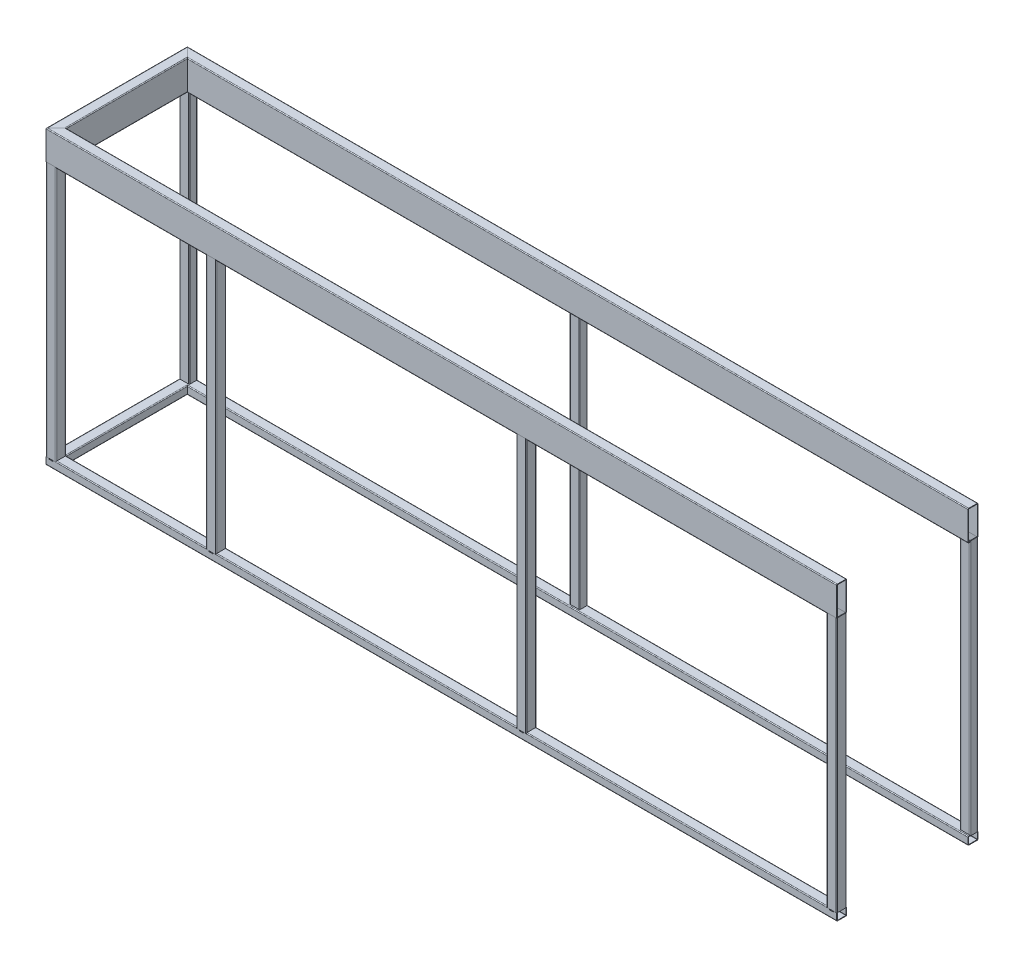
from build123d import *

# Parameters (mm, degrees)
VIERKANTROHRE_150X50X3_1_DEPTH        = 3981.056941504
VIERKANTROHRE_150X50X3_1_2_DEPTH      = 816.113883008
VIERKANTROHRE_150X50X3_1_3_DEPTH      = 3901
VIERKANTROHRE_150X50X3_1_3_DEPTH_BACK = 80.056941504
VIERKANTROHRE_50X50X3_1_DEPTH         = 1363
VIERKANTROHRE_50X50X3_1_2_DEPTH       = 1363
VIERKANTROHRE_50X50X3_1_3_DEPTH       = 1363
VIERKANTROHRE_50X50X3_1_4_DEPTH       = 1363
VIERKANTROHRE_40X50X3_1_DEPTH         = 3934.015621187
VIERKANTROHRE_40X50X3_1_2_DEPTH       = 722.031242374
VIERKANTROHRE_40X50X3_1_3_DEPTH       = 3901
VIERKANTROHRE_40X50X3_1_3_DEPTH_BACK  = 33.015621187
PART_START                            = 316.227766017
PART_RUN_ON_DEPTH                     = 341.227766017
BODY_START                            = 3584.772233983
BODY_3_RUN_ON_DEPTH                   = 341.227766017
BODY_START_2                          = 128.062484749
BODY_8_RUN_ON_DEPTH                   = 153.062484749
BODY_START_3                          = 3772.937515251
BODY_10_RUN_ON_DEPTH                  = 153.062484749
SKIZZE16_W                            = 50
SKIZZE16_H                            = 4
SCHNITT_LINEAR_AUSTRAGEN1_DEPTH       = 50
SKIZZE17_W                            = 50
SKIZZE17_H                            = 4
SCHNITT_LINEAR_AUSTRAGEN2_DEPTH       = 40
VIERKANTROHRE_40X50X3_5_DEPTH         = 1363
VIERKANTROHRE_40X50X3_5_2_DEPTH       = 1363
VIERKANTROHRE_40X50X3_5_3_DEPTH       = 1363


with BuildPart() as part:
    # Skizze1 on segment 1 (carried to segment 1) → Vierkantrohre 150X50X3(1) (new body)
    with BuildSketch(Plane(origin=(3901, 0, 0), x_dir=(0, 1, 0), z_dir=(-1, 0, 0))):
        with BuildLine():
            Line((-71, 25), (71, 25))
            ThreePointArc((71, 25), (73.828427125, 23.828427125), (75, 21))
            Line((75, 21), (75, -21))
            ThreePointArc((75, -21), (73.828427125, -23.828427125), (71, -25))
            Line((71, -25), (-71, -25))
            ThreePointArc((-71, -25), (-73.828427125, -23.828427125), (-75, -21))
            Line((-75, -21), (-75, 21))
            ThreePointArc((-75, 21), (-73.828427125, 23.828427125), (-71, 25))
        make_face()
        with BuildLine():
            Line((-71, 22), (71, 22))
            ThreePointArc((71, 22), (71.707106781, 21.707106781), (72, 21))
            Line((72, 21), (72, -21))
            ThreePointArc((72, -21), (71.707106781, -21.707106781), (71, -22))
            Line((71, -22), (-71, -22))
            ThreePointArc((-71, -22), (-71.707106781, -21.707106781), (-72, -21))
            Line((-72, -21), (-72, 21))
            ThreePointArc((-72, 21), (-71.707106781, 21.707106781), (-71, 22))
        make_face(mode=Mode.SUBTRACT)
    extrude(amount=VIERKANTROHRE_150X50X3_1_DEPTH)

    # Vierkantrohre 150X50X3(1) mitre 1
    split(bisect_by=Plane(origin=(0, 0, 0), x_dir=(0, 1, 0), z_dir=(0.707106781, 0, 0.707106781)), keep=Keep.TOP)

    # part cut square before the run-on
    split(bisect_by=Plane(origin=(3584.772233983, 0, 0), x_dir=(0, -1, 0), z_dir=(-1, 0, 0)), keep=Keep.TOP)

    # Skizze1 on segment 1 (carried to segment 1) → part run on (add)
    with BuildSketch(Plane(origin=(3901, 0, 0), x_dir=(0, 1, 0), z_dir=(-1, 0, 0)).offset(PART_START)):
        with BuildLine():
            Line((-71, 25), (71, 25))
            ThreePointArc((71, 25), (73.828427125, 23.828427125), (75, 21))
            Line((75, 21), (75, -21))
            ThreePointArc((75, -21), (73.828427125, -23.828427125), (71, -25))
            Line((71, -25), (-71, -25))
            ThreePointArc((-71, -25), (-73.828427125, -23.828427125), (-75, -21))
            Line((-75, -21), (-75, 21))
            ThreePointArc((-75, 21), (-73.828427125, 23.828427125), (-71, 25))
        make_face()
        with BuildLine():
            Line((-71, 22), (71, 22))
            ThreePointArc((71, 22), (71.707106781, 21.707106781), (72, 21))
            Line((72, 21), (72, -21))
            ThreePointArc((72, -21), (71.707106781, -21.707106781), (71, -22))
            Line((71, -22), (-71, -22))
            ThreePointArc((-71, -22), (-71.707106781, -21.707106781), (-72, -21))
            Line((-72, -21), (-72, 21))
            ThreePointArc((-72, 21), (-71.707106781, 21.707106781), (-71, 22))
        make_face(mode=Mode.SUBTRACT)
    extrude(amount=-PART_RUN_ON_DEPTH)


with BuildPart() as body_2:
    # Skizze1 on segment 2 (carried to segment 2) → Vierkantrohre 150X50X3_1 2 (new body)
    with BuildSketch(Plane.YX.offset(-80.056941504)):
        with BuildLine():
            Line((-71, 25), (71, 25))
            ThreePointArc((71, 25), (73.828427125, 23.828427125), (75, 21))
            Line((75, 21), (75, -21))
            ThreePointArc((75, -21), (73.828427125, -23.828427125), (71, -25))
            Line((71, -25), (-71, -25))
            ThreePointArc((-71, -25), (-73.828427125, -23.828427125), (-75, -21))
            Line((-75, -21), (-75, 21))
            ThreePointArc((-75, 21), (-73.828427125, 23.828427125), (-71, 25))
        make_face()
        with BuildLine():
            Line((-71, 22), (71, 22))
            ThreePointArc((71, 22), (71.707106781, 21.707106781), (72, 21))
            Line((72, 21), (72, -21))
            ThreePointArc((72, -21), (71.707106781, -21.707106781), (71, -22))
            Line((71, -22), (-71, -22))
            ThreePointArc((-71, -22), (-71.707106781, -21.707106781), (-72, -21))
            Line((-72, -21), (-72, 21))
            ThreePointArc((-72, 21), (-71.707106781, 21.707106781), (-71, 22))
        make_face(mode=Mode.SUBTRACT)
    extrude(amount=VIERKANTROHRE_150X50X3_1_2_DEPTH)

    # Vierkantrohre 150X50X3_1 2 mitre 1
    split(bisect_by=Plane(origin=(0, 0, 0), x_dir=(0, -1, 0), z_dir=(-0.707106781, 0, -0.707106781)), keep=Keep.TOP)

    # Vierkantrohre 150X50X3_1 2 mitre 2
    split(bisect_by=Plane(origin=(0, 0, -656), x_dir=(0, -1, 0), z_dir=(-0.707106781, 0, 0.707106781)), keep=Keep.TOP)


with BuildPart() as body_3:
    # Skizze1 → Vierkantrohre 150X50X3_1 3 (new, two sides)
    with BuildSketch(Plane(origin=(0, 0, -656), x_dir=(0, 1, 0), z_dir=(1, 0, 0))) as vierkantrohre_150x50x3_1_3_sk:
        with BuildLine():
            Line((-71, 25), (71, 25))
            ThreePointArc((71, 25), (73.828427125, 23.828427125), (75, 21))
            Line((75, 21), (75, -21))
            ThreePointArc((75, -21), (73.828427125, -23.828427125), (71, -25))
            Line((71, -25), (-71, -25))
            ThreePointArc((-71, -25), (-73.828427125, -23.828427125), (-75, -21))
            Line((-75, -21), (-75, 21))
            ThreePointArc((-75, 21), (-73.828427125, 23.828427125), (-71, 25))
        make_face()
        with BuildLine():
            Line((-71, 22), (71, 22))
            ThreePointArc((71, 22), (71.707106781, 21.707106781), (72, 21))
            Line((72, 21), (72, -21))
            ThreePointArc((72, -21), (71.707106781, -21.707106781), (71, -22))
            Line((71, -22), (-71, -22))
            ThreePointArc((-71, -22), (-71.707106781, -21.707106781), (-72, -21))
            Line((-72, -21), (-72, 21))
            ThreePointArc((-72, 21), (-71.707106781, 21.707106781), (-71, 22))
        make_face(mode=Mode.SUBTRACT)
    extrude(amount=VIERKANTROHRE_150X50X3_1_3_DEPTH)
    extrude(vierkantrohre_150x50x3_1_3_sk.sketch, amount=-VIERKANTROHRE_150X50X3_1_3_DEPTH_BACK)

    # Vierkantrohre 150X50X3_1 3 mitre 1
    split(bisect_by=Plane(origin=(0, 0, -656), x_dir=(0, 1, 0), z_dir=(0.707106781, 0, -0.707106781)), keep=Keep.TOP)

    # body 3 cut square before the run-on
    split(bisect_by=Plane(origin=(3584.772233983, 0, -656), x_dir=(0, -1, 0), z_dir=(-1, 0, 0)), keep=Keep.TOP)

    # Skizze1 → body 3 run on (add)
    with BuildSketch(Plane(origin=(0, 0, -656), x_dir=(0, 1, 0), z_dir=(1, 0, 0)).offset(BODY_START)):
        with BuildLine():
            Line((-71, 25), (71, 25))
            ThreePointArc((71, 25), (73.828427125, 23.828427125), (75, 21))
            Line((75, 21), (75, -21))
            ThreePointArc((75, -21), (73.828427125, -23.828427125), (71, -25))
            Line((71, -25), (-71, -25))
            ThreePointArc((-71, -25), (-73.828427125, -23.828427125), (-75, -21))
            Line((-75, -21), (-75, 21))
            ThreePointArc((-75, 21), (-73.828427125, 23.828427125), (-71, 25))
        make_face()
        with BuildLine():
            Line((-71, 22), (71, 22))
            ThreePointArc((71, 22), (71.707106781, 21.707106781), (72, 21))
            Line((72, 21), (72, -21))
            ThreePointArc((72, -21), (71.707106781, -21.707106781), (71, -22))
            Line((71, -22), (-71, -22))
            ThreePointArc((-71, -22), (-71.707106781, -21.707106781), (-72, -21))
            Line((-72, -21), (-72, 21))
            ThreePointArc((-72, 21), (-71.707106781, 21.707106781), (-71, 22))
        make_face(mode=Mode.SUBTRACT)
    extrude(amount=BODY_3_RUN_ON_DEPTH)


with BuildPart() as body_4:
    # Skizze13 → Vierkantrohre 50X50X3(1) (new body)
    with BuildSketch(Plane.XZ):
        with BuildLine():
            Line((-21, 25), (21, 25))
            ThreePointArc((21, 25), (23.828427125, 23.828427125), (25, 21))
            Line((25, 21), (25, -21))
            ThreePointArc((25, -21), (23.828427125, -23.828427125), (21, -25))
            Line((21, -25), (-21, -25))
            ThreePointArc((-21, -25), (-23.828427125, -23.828427125), (-25, -21))
            Line((-25, -21), (-25, 21))
            ThreePointArc((-25, 21), (-23.828427125, 23.828427125), (-21, 25))
        make_face()
        with BuildLine():
            Line((-21, 22), (21, 22))
            ThreePointArc((21, 22), (21.707106781, 21.707106781), (22, 21))
            Line((22, 21), (22, -21))
            ThreePointArc((22, -21), (21.707106781, -21.707106781), (21, -22))
            Line((21, -22), (-21, -22))
            ThreePointArc((-21, -22), (-21.707106781, -21.707106781), (-22, -21))
            Line((-22, -21), (-22, 21))
            ThreePointArc((-22, 21), (-21.707106781, 21.707106781), (-21, 22))
        make_face(mode=Mode.SUBTRACT)
    extrude(amount=VIERKANTROHRE_50X50X3_1_DEPTH)

    # Trimmen/Verlängern5
    split(bisect_by=Plane(origin=(3883.5, -1347, 23.5), x_dir=(-1, 0, 0), z_dir=(0, 1, 0)), keep=Keep.TOP)

    # Trimmen_Verl_ngern5 3
    split(bisect_by=Plane(origin=(3901, -71, 23.5), x_dir=(1, 0, 0), z_dir=(0, -1, 0)), keep=Keep.TOP)


with BuildPart() as body_5:
    # Skizze13 on segment 2 (carried to segment 2) → Vierkantrohre 50X50X3_1 2 (new body)
    with BuildSketch(Plane(origin=(800, 0, 0), x_dir=(1, 0, 0), z_dir=(0, -1, 0))):
        with BuildLine():
            Line((-21, 25), (21, 25))
            ThreePointArc((21, 25), (23.828427125, 23.828427125), (25, 21))
            Line((25, 21), (25, -21))
            ThreePointArc((25, -21), (23.828427125, -23.828427125), (21, -25))
            Line((21, -25), (-21, -25))
            ThreePointArc((-21, -25), (-23.828427125, -23.828427125), (-25, -21))
            Line((-25, -21), (-25, 21))
            ThreePointArc((-25, 21), (-23.828427125, 23.828427125), (-21, 25))
        make_face()
        with BuildLine():
            Line((-21, 22), (21, 22))
            ThreePointArc((21, 22), (21.707106781, 21.707106781), (22, 21))
            Line((22, 21), (22, -21))
            ThreePointArc((22, -21), (21.707106781, -21.707106781), (21, -22))
            Line((21, -22), (-21, -22))
            ThreePointArc((-21, -22), (-21.707106781, -21.707106781), (-22, -21))
            Line((-22, -21), (-22, 21))
            ThreePointArc((-22, 21), (-21.707106781, 21.707106781), (-21, 22))
        make_face(mode=Mode.SUBTRACT)
    extrude(amount=VIERKANTROHRE_50X50X3_1_2_DEPTH)

    # Trimmen/Verlängern5
    split(bisect_by=Plane(origin=(3883.5, -1347, 23.5), x_dir=(-1, 0, 0), z_dir=(0, 1, 0)), keep=Keep.TOP)

    # Trimmen_Verl_ngern5 3
    split(bisect_by=Plane(origin=(3901, -71, 23.5), x_dir=(1, 0, 0), z_dir=(0, -1, 0)), keep=Keep.TOP)


with BuildPart() as body_6:
    # Skizze13 on segment 3 (carried to segment 3) → Vierkantrohre 50X50X3_1 3 (new body)
    with BuildSketch(Plane(origin=(2350, 0, 0), x_dir=(1, 0, 0), z_dir=(0, -1, 0))):
        with BuildLine():
            Line((-21, 25), (21, 25))
            ThreePointArc((21, 25), (23.828427125, 23.828427125), (25, 21))
            Line((25, 21), (25, -21))
            ThreePointArc((25, -21), (23.828427125, -23.828427125), (21, -25))
            Line((21, -25), (-21, -25))
            ThreePointArc((-21, -25), (-23.828427125, -23.828427125), (-25, -21))
            Line((-25, -21), (-25, 21))
            ThreePointArc((-25, 21), (-23.828427125, 23.828427125), (-21, 25))
        make_face()
        with BuildLine():
            Line((-21, 22), (21, 22))
            ThreePointArc((21, 22), (21.707106781, 21.707106781), (22, 21))
            Line((22, 21), (22, -21))
            ThreePointArc((22, -21), (21.707106781, -21.707106781), (21, -22))
            Line((21, -22), (-21, -22))
            ThreePointArc((-21, -22), (-21.707106781, -21.707106781), (-22, -21))
            Line((-22, -21), (-22, 21))
            ThreePointArc((-22, 21), (-21.707106781, 21.707106781), (-21, 22))
        make_face(mode=Mode.SUBTRACT)
    extrude(amount=VIERKANTROHRE_50X50X3_1_3_DEPTH)

    # Trimmen/Verlängern5
    split(bisect_by=Plane(origin=(3883.5, -1347, 23.5), x_dir=(-1, 0, 0), z_dir=(0, 1, 0)), keep=Keep.TOP)

    # Trimmen_Verl_ngern5 3
    split(bisect_by=Plane(origin=(3901, -71, 23.5), x_dir=(1, 0, 0), z_dir=(0, -1, 0)), keep=Keep.TOP)


with BuildPart() as body_7:
    # Skizze13 on segment 4 (carried to segment 4) → Vierkantrohre 50X50X3_1 4 (new body)
    with BuildSketch(Plane(origin=(3901, 0, 0), x_dir=(1, 0, 0), z_dir=(0, -1, 0))):
        with BuildLine():
            Line((-21, 25), (21, 25))
            ThreePointArc((21, 25), (23.828427125, 23.828427125), (25, 21))
            Line((25, 21), (25, -21))
            ThreePointArc((25, -21), (23.828427125, -23.828427125), (21, -25))
            Line((21, -25), (-21, -25))
            ThreePointArc((-21, -25), (-23.828427125, -23.828427125), (-25, -21))
            Line((-25, -21), (-25, 21))
            ThreePointArc((-25, 21), (-23.828427125, 23.828427125), (-21, 25))
        make_face()
        with BuildLine():
            Line((-21, 22), (21, 22))
            ThreePointArc((21, 22), (21.707106781, 21.707106781), (22, 21))
            Line((22, 21), (22, -21))
            ThreePointArc((22, -21), (21.707106781, -21.707106781), (21, -22))
            Line((21, -22), (-21, -22))
            ThreePointArc((-21, -22), (-21.707106781, -21.707106781), (-22, -21))
            Line((-22, -21), (-22, 21))
            ThreePointArc((-22, 21), (-21.707106781, 21.707106781), (-21, 22))
        make_face(mode=Mode.SUBTRACT)
    extrude(amount=VIERKANTROHRE_50X50X3_1_4_DEPTH)

    # Trimmen/Verlängern5
    split(bisect_by=Plane(origin=(3883.5, -1347, 23.5), x_dir=(-1, 0, 0), z_dir=(0, 1, 0)), keep=Keep.TOP)

    # Trimmen_Verl_ngern5 3
    split(bisect_by=Plane(origin=(3901, -71, 23.5), x_dir=(1, 0, 0), z_dir=(0, -1, 0)), keep=Keep.TOP)


with BuildPart() as body_8:
    # Skizze15 on segment 1 (carried to segment 1) → Vierkantrohre 40X50X3(1) (new body)
    with BuildSketch(Plane(origin=(3901, -1363, 0), x_dir=(0, 1, 0), z_dir=(-1, 0, 0))):
        with BuildLine():
            Line((-16, 25), (16, 25))
            ThreePointArc((16, 25), (18.828427125, 23.828427125), (20, 21))
            Line((20, 21), (20, -21))
            ThreePointArc((20, -21), (18.828427125, -23.828427125), (16, -25))
            Line((16, -25), (-16, -25))
            ThreePointArc((-16, -25), (-18.828427125, -23.828427125), (-20, -21))
            Line((-20, -21), (-20, 21))
            ThreePointArc((-20, 21), (-18.828427125, 23.828427125), (-16, 25))
        make_face()
        with BuildLine():
            Line((-16, 22), (16, 22))
            ThreePointArc((16, 22), (16.707106781, 21.707106781), (17, 21))
            Line((17, 21), (17, -21))
            ThreePointArc((17, -21), (16.707106781, -21.707106781), (16, -22))
            Line((16, -22), (-16, -22))
            ThreePointArc((-16, -22), (-16.707106781, -21.707106781), (-17, -21))
            Line((-17, -21), (-17, 21))
            ThreePointArc((-17, 21), (-16.707106781, 21.707106781), (-16, 22))
        make_face(mode=Mode.SUBTRACT)
    extrude(amount=VIERKANTROHRE_40X50X3_1_DEPTH)

    # Vierkantrohre 40X50X3(1) mitre 1
    split(bisect_by=Plane(origin=(0, -1363, 0), x_dir=(0, 1, 0), z_dir=(0.707106781, 0, 0.707106781)), keep=Keep.TOP)

    # body 8 cut square before the run-on
    split(bisect_by=Plane(origin=(3772.937515251, -1363, 0), x_dir=(0, -1, 0), z_dir=(-1, 0, 0)), keep=Keep.TOP)

    # Skizze15 on segment 1 (carried to segment 1) → body 8 run on (add)
    with BuildSketch(Plane(origin=(3901, -1363, 0), x_dir=(0, 1, 0), z_dir=(-1, 0, 0)).offset(BODY_START_2)):
        with BuildLine():
            Line((-16, 25), (16, 25))
            ThreePointArc((16, 25), (18.828427125, 23.828427125), (20, 21))
            Line((20, 21), (20, -21))
            ThreePointArc((20, -21), (18.828427125, -23.828427125), (16, -25))
            Line((16, -25), (-16, -25))
            ThreePointArc((-16, -25), (-18.828427125, -23.828427125), (-20, -21))
            Line((-20, -21), (-20, 21))
            ThreePointArc((-20, 21), (-18.828427125, 23.828427125), (-16, 25))
        make_face()
        with BuildLine():
            Line((-16, 22), (16, 22))
            ThreePointArc((16, 22), (16.707106781, 21.707106781), (17, 21))
            Line((17, 21), (17, -21))
            ThreePointArc((17, -21), (16.707106781, -21.707106781), (16, -22))
            Line((16, -22), (-16, -22))
            ThreePointArc((-16, -22), (-16.707106781, -21.707106781), (-17, -21))
            Line((-17, -21), (-17, 21))
            ThreePointArc((-17, 21), (-16.707106781, 21.707106781), (-16, 22))
        make_face(mode=Mode.SUBTRACT)
    extrude(amount=-BODY_8_RUN_ON_DEPTH)


with BuildPart() as body_9:
    # Skizze15 on segment 2 (carried to segment 2) → Vierkantrohre 40X50X3_1 2 (new body)
    with BuildSketch(Plane(origin=(0, -1363, 33.015621187), x_dir=(0, 1, 0), z_dir=(0, 0, -1))):
        with BuildLine():
            Line((-16, 25), (16, 25))
            ThreePointArc((16, 25), (18.828427125, 23.828427125), (20, 21))
            Line((20, 21), (20, -21))
            ThreePointArc((20, -21), (18.828427125, -23.828427125), (16, -25))
            Line((16, -25), (-16, -25))
            ThreePointArc((-16, -25), (-18.828427125, -23.828427125), (-20, -21))
            Line((-20, -21), (-20, 21))
            ThreePointArc((-20, 21), (-18.828427125, 23.828427125), (-16, 25))
        make_face()
        with BuildLine():
            Line((-16, 22), (16, 22))
            ThreePointArc((16, 22), (16.707106781, 21.707106781), (17, 21))
            Line((17, 21), (17, -21))
            ThreePointArc((17, -21), (16.707106781, -21.707106781), (16, -22))
            Line((16, -22), (-16, -22))
            ThreePointArc((-16, -22), (-16.707106781, -21.707106781), (-17, -21))
            Line((-17, -21), (-17, 21))
            ThreePointArc((-17, 21), (-16.707106781, 21.707106781), (-16, 22))
        make_face(mode=Mode.SUBTRACT)
    extrude(amount=VIERKANTROHRE_40X50X3_1_2_DEPTH)

    # Vierkantrohre 40X50X3_1 2 mitre 1
    split(bisect_by=Plane(origin=(0, -1363, -656), x_dir=(0, -1, 0), z_dir=(-0.707106781, 0, 0.707106781)), keep=Keep.TOP)

    # Vierkantrohre 40X50X3_1 2 mitre 2
    split(bisect_by=Plane(origin=(0, -1363, 0), x_dir=(0, -1, 0), z_dir=(-0.707106781, 0, -0.707106781)), keep=Keep.TOP)


with BuildPart() as body_10:
    # Skizze15 → Vierkantrohre 40X50X3_1 3 (new, two sides)
    with BuildSketch(Plane(origin=(0, -1363, -656), x_dir=(0, 1, 0), z_dir=(1, 0, 0))) as vierkantrohre_40x50x3_1_3_sk:
        with BuildLine():
            Line((-16, 25), (16, 25))
            ThreePointArc((16, 25), (18.828427125, 23.828427125), (20, 21))
            Line((20, 21), (20, -21))
            ThreePointArc((20, -21), (18.828427125, -23.828427125), (16, -25))
            Line((16, -25), (-16, -25))
            ThreePointArc((-16, -25), (-18.828427125, -23.828427125), (-20, -21))
            Line((-20, -21), (-20, 21))
            ThreePointArc((-20, 21), (-18.828427125, 23.828427125), (-16, 25))
        make_face()
        with BuildLine():
            Line((-16, 22), (16, 22))
            ThreePointArc((16, 22), (16.707106781, 21.707106781), (17, 21))
            Line((17, 21), (17, -21))
            ThreePointArc((17, -21), (16.707106781, -21.707106781), (16, -22))
            Line((16, -22), (-16, -22))
            ThreePointArc((-16, -22), (-16.707106781, -21.707106781), (-17, -21))
            Line((-17, -21), (-17, 21))
            ThreePointArc((-17, 21), (-16.707106781, 21.707106781), (-16, 22))
        make_face(mode=Mode.SUBTRACT)
    extrude(amount=VIERKANTROHRE_40X50X3_1_3_DEPTH)
    extrude(vierkantrohre_40x50x3_1_3_sk.sketch, amount=-VIERKANTROHRE_40X50X3_1_3_DEPTH_BACK)

    # Vierkantrohre 40X50X3_1 3 mitre 1
    split(bisect_by=Plane(origin=(0, -1363, -656), x_dir=(0, 1, 0), z_dir=(0.707106781, 0, -0.707106781)), keep=Keep.TOP)

    # body 10 cut square before the run-on
    split(bisect_by=Plane(origin=(3772.937515251, -1363, -656), x_dir=(0, -1, 0), z_dir=(-1, 0, 0)), keep=Keep.TOP)

    # Skizze15 → body 10 run on (add)
    with BuildSketch(Plane(origin=(0, -1363, -656), x_dir=(0, 1, 0), z_dir=(1, 0, 0)).offset(BODY_START_3)):
        with BuildLine():
            Line((-16, 25), (16, 25))
            ThreePointArc((16, 25), (18.828427125, 23.828427125), (20, 21))
            Line((20, 21), (20, -21))
            ThreePointArc((20, -21), (18.828427125, -23.828427125), (16, -25))
            Line((16, -25), (-16, -25))
            ThreePointArc((-16, -25), (-18.828427125, -23.828427125), (-20, -21))
            Line((-20, -21), (-20, 21))
            ThreePointArc((-20, 21), (-18.828427125, 23.828427125), (-16, 25))
        make_face()
        with BuildLine():
            Line((-16, 22), (16, 22))
            ThreePointArc((16, 22), (16.707106781, 21.707106781), (17, 21))
            Line((17, 21), (17, -21))
            ThreePointArc((17, -21), (16.707106781, -21.707106781), (16, -22))
            Line((16, -22), (-16, -22))
            ThreePointArc((-16, -22), (-16.707106781, -21.707106781), (-17, -21))
            Line((-17, -21), (-17, 21))
            ThreePointArc((-17, 21), (-16.707106781, 21.707106781), (-16, 22))
        make_face(mode=Mode.SUBTRACT)
    extrude(amount=BODY_10_RUN_ON_DEPTH)


with BuildPart() as schnitt_linear_austragen1_tool:
    # Skizze16 → Schnitt-Linear austragen1 (new body)
    with BuildSketch(Plane.XY.offset(25)):
        Polygon((25, -1343), (25, -1347), (10, -1347), (10, -1351), (-10, -1351), (-10, -1347), (-25, -1347), (-25, -1343), align=None)
        Polygon((775, -1343), (775, -1347), (790, -1347), (790, -1351), (810, -1351), (810, -1347), (825, -1347), (825, -1343), align=None)
        with Locations((0, -73)):
            Rectangle(SKIZZE16_W, SKIZZE16_H)
        Polygon((2325, -1347), (2340, -1347), (2340, -1351), (2360, -1351), (2360, -1347), (2375, -1347), (2375, -1343), (2325, -1343), align=None)
        Polygon((3876, -1343), (3876, -1347), (3891, -1347), (3891, -1351), (3911, -1351), (3911, -1347), (3926, -1347), (3926, -1343), align=None)
        with Locations((800, -73)):
            Rectangle(SKIZZE16_W, SKIZZE16_H)
        with Locations((2350, -73)):
            Rectangle(SKIZZE16_W, SKIZZE16_H)
        with Locations((3901, -73)):
            Rectangle(SKIZZE16_W, SKIZZE16_H)
    extrude(amount=-SCHNITT_LINEAR_AUSTRAGEN1_DEPTH)


with BuildPart() as body_8_1:
    add(body_8.part)

    # Schnitt-Linear austragen1: cut by schnitt_linear_austragen1_tool
    add(schnitt_linear_austragen1_tool.part, mode=Mode.SUBTRACT)


with BuildPart() as body_9_1:
    add(body_9.part)

    # Schnitt-Linear austragen1: cut by schnitt_linear_austragen1_tool
    add(schnitt_linear_austragen1_tool.part, mode=Mode.SUBTRACT)


with BuildPart() as part_1:
    add(part.part)

    # Schnitt-Linear austragen1: cut by schnitt_linear_austragen1_tool
    add(schnitt_linear_austragen1_tool.part, mode=Mode.SUBTRACT)


with BuildPart() as body_2_1:
    add(body_2.part)

    # Schnitt-Linear austragen1: cut by schnitt_linear_austragen1_tool
    add(schnitt_linear_austragen1_tool.part, mode=Mode.SUBTRACT)


with BuildPart() as schnitt_linear_austragen2_tool:
    # Skizze17 → Schnitt-Linear austragen2 (new body)
    with BuildSketch(Plane(origin=(0, 0, -681), x_dir=(-1, 0, 0), z_dir=(0, 0, -1))):
        with Locations((-3901, -1345)):
            Rectangle(SKIZZE17_W, SKIZZE17_H)
        with Locations((-1950.5, -1345)):
            Rectangle(SKIZZE17_W, SKIZZE17_H)
        with Locations((0, -1345)):
            Rectangle(SKIZZE17_W, SKIZZE17_H)
        with Locations((-3901, -73)):
            Rectangle(SKIZZE17_W, SKIZZE17_H)
        with Locations((-1950.5, -73)):
            Rectangle(SKIZZE17_W, SKIZZE17_H)
        with Locations((0, -73)):
            Rectangle(SKIZZE17_W, SKIZZE17_H)
    extrude(amount=-SCHNITT_LINEAR_AUSTRAGEN2_DEPTH)


with BuildPart() as body_2_2:
    add(body_2_1.part)

    # Schnitt-Linear austragen2: cut by schnitt_linear_austragen2_tool
    add(schnitt_linear_austragen2_tool.part, mode=Mode.SUBTRACT)


with BuildPart() as body_3_1:
    add(body_3.part)

    # Schnitt-Linear austragen2: cut by schnitt_linear_austragen2_tool
    add(schnitt_linear_austragen2_tool.part, mode=Mode.SUBTRACT)


with BuildPart() as body_9_2:
    add(body_9_1.part)

    # Schnitt-Linear austragen2: cut by schnitt_linear_austragen2_tool
    add(schnitt_linear_austragen2_tool.part, mode=Mode.SUBTRACT)


with BuildPart() as body_10_1:
    add(body_10.part)

    # Schnitt-Linear austragen2: cut by schnitt_linear_austragen2_tool
    add(schnitt_linear_austragen2_tool.part, mode=Mode.SUBTRACT)


with BuildPart() as body_11:
    # Skizze19 → Vierkantrohre 40X50X3(5) (new body)
    with BuildSketch(Plane(origin=(3901, 0, -661), x_dir=(0, 0, 1), z_dir=(0, -1, 0))):
        with BuildLine():
            Line((-16, 25), (16, 25))
            ThreePointArc((16, 25), (18.828427125, 23.828427125), (20, 21))
            Line((20, 21), (20, -21))
            ThreePointArc((20, -21), (18.828427125, -23.828427125), (16, -25))
            Line((16, -25), (-16, -25))
            ThreePointArc((-16, -25), (-18.828427125, -23.828427125), (-20, -21))
            Line((-20, -21), (-20, 21))
            ThreePointArc((-20, 21), (-18.828427125, 23.828427125), (-16, 25))
        make_face()
        with BuildLine():
            Line((-16, 22), (16, 22))
            ThreePointArc((16, 22), (16.707106781, 21.707106781), (17, 21))
            Line((17, 21), (17, -21))
            ThreePointArc((17, -21), (16.707106781, -21.707106781), (16, -22))
            Line((16, -22), (-16, -22))
            ThreePointArc((-16, -22), (-16.707106781, -21.707106781), (-17, -21))
            Line((-17, -21), (-17, 21))
            ThreePointArc((-17, 21), (-16.707106781, 21.707106781), (-16, 22))
        make_face(mode=Mode.SUBTRACT)
    extrude(amount=VIERKANTROHRE_40X50X3_5_DEPTH)

    # Trimmen/Verlängern6
    split(bisect_by=Plane(origin=(0.742268041, -71, -679.515463918), x_dir=(1, 0, 0), z_dir=(0, -1, 0)), keep=Keep.TOP)

    # Trimmen_Verl_ngern6 3
    split(bisect_by=Plane(origin=(0.742268041, -1347, -679.515463918), x_dir=(-1, 0, 0), z_dir=(0, 1, 0)), keep=Keep.TOP)


with BuildPart() as body_12:
    # Skizze19 on segment 2 (carried to segment 2) → Vierkantrohre 40X50X3_5 2 (new body)
    with BuildSketch(Plane(origin=(1950.5, 0, -661), x_dir=(0, 0, 1), z_dir=(0, -1, 0))):
        with BuildLine():
            Line((-16, 25), (16, 25))
            ThreePointArc((16, 25), (18.828427125, 23.828427125), (20, 21))
            Line((20, 21), (20, -21))
            ThreePointArc((20, -21), (18.828427125, -23.828427125), (16, -25))
            Line((16, -25), (-16, -25))
            ThreePointArc((-16, -25), (-18.828427125, -23.828427125), (-20, -21))
            Line((-20, -21), (-20, 21))
            ThreePointArc((-20, 21), (-18.828427125, 23.828427125), (-16, 25))
        make_face()
        with BuildLine():
            Line((-16, 22), (16, 22))
            ThreePointArc((16, 22), (16.707106781, 21.707106781), (17, 21))
            Line((17, 21), (17, -21))
            ThreePointArc((17, -21), (16.707106781, -21.707106781), (16, -22))
            Line((16, -22), (-16, -22))
            ThreePointArc((-16, -22), (-16.707106781, -21.707106781), (-17, -21))
            Line((-17, -21), (-17, 21))
            ThreePointArc((-17, 21), (-16.707106781, 21.707106781), (-16, 22))
        make_face(mode=Mode.SUBTRACT)
    extrude(amount=VIERKANTROHRE_40X50X3_5_2_DEPTH)

    # Trimmen/Verlängern6
    split(bisect_by=Plane(origin=(0.742268041, -71, -679.515463918), x_dir=(1, 0, 0), z_dir=(0, -1, 0)), keep=Keep.TOP)

    # Trimmen_Verl_ngern6 3
    split(bisect_by=Plane(origin=(0.742268041, -1347, -679.515463918), x_dir=(-1, 0, 0), z_dir=(0, 1, 0)), keep=Keep.TOP)


with BuildPart() as body_13:
    # Skizze19 on segment 3 (carried to segment 3) → Vierkantrohre 40X50X3_5 3 (new body)
    with BuildSketch(Plane(origin=(0, 0, -661), x_dir=(0, 0, 1), z_dir=(0, -1, 0))):
        with BuildLine():
            Line((-16, 25), (16, 25))
            ThreePointArc((16, 25), (18.828427125, 23.828427125), (20, 21))
            Line((20, 21), (20, -21))
            ThreePointArc((20, -21), (18.828427125, -23.828427125), (16, -25))
            Line((16, -25), (-16, -25))
            ThreePointArc((-16, -25), (-18.828427125, -23.828427125), (-20, -21))
            Line((-20, -21), (-20, 21))
            ThreePointArc((-20, 21), (-18.828427125, 23.828427125), (-16, 25))
        make_face()
        with BuildLine():
            Line((-16, 22), (16, 22))
            ThreePointArc((16, 22), (16.707106781, 21.707106781), (17, 21))
            Line((17, 21), (17, -21))
            ThreePointArc((17, -21), (16.707106781, -21.707106781), (16, -22))
            Line((16, -22), (-16, -22))
            ThreePointArc((-16, -22), (-16.707106781, -21.707106781), (-17, -21))
            Line((-17, -21), (-17, 21))
            ThreePointArc((-17, 21), (-16.707106781, 21.707106781), (-16, 22))
        make_face(mode=Mode.SUBTRACT)
    extrude(amount=VIERKANTROHRE_40X50X3_5_3_DEPTH)

    # Trimmen/Verlängern6
    split(bisect_by=Plane(origin=(0.742268041, -71, -679.515463918), x_dir=(1, 0, 0), z_dir=(0, -1, 0)), keep=Keep.TOP)

    # Trimmen_Verl_ngern6 3
    split(bisect_by=Plane(origin=(0.742268041, -1347, -679.515463918), x_dir=(-1, 0, 0), z_dir=(0, 1, 0)), keep=Keep.TOP)


solid = Compound([body_4.part, body_5.part, body_6.part, body_7.part, body_8_1.part, part_1.part, body_2_2.part, body_3_1.part, body_9_2.part, body_10_1.part, body_11.part, body_12.part, body_13.part])
